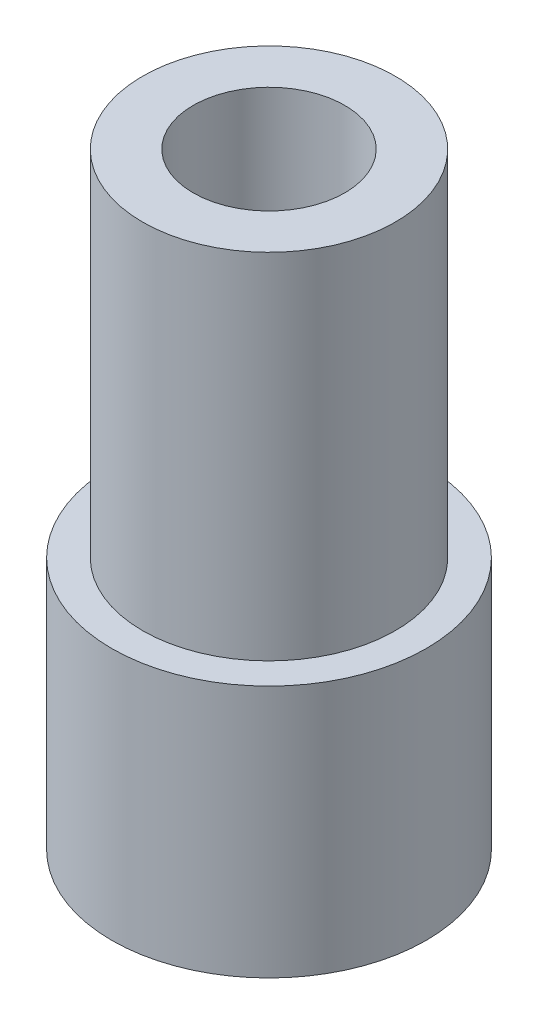
from build123d import *


with BuildPart() as part:
    # Esquisse1 → Révolution1 (revolve)
    with BuildSketch(Plane.XY):
        Polygon((1.5, 3.5), (1.5, -8.5), (3.111111111, -8.5), (3.111111111, -3.5), (2.5, -3.5), (2.5, 3.5), align=None)
    revolve(axis=Axis((0, 8.626576325, 0), (0, -1, 0)))


solid = part.part
